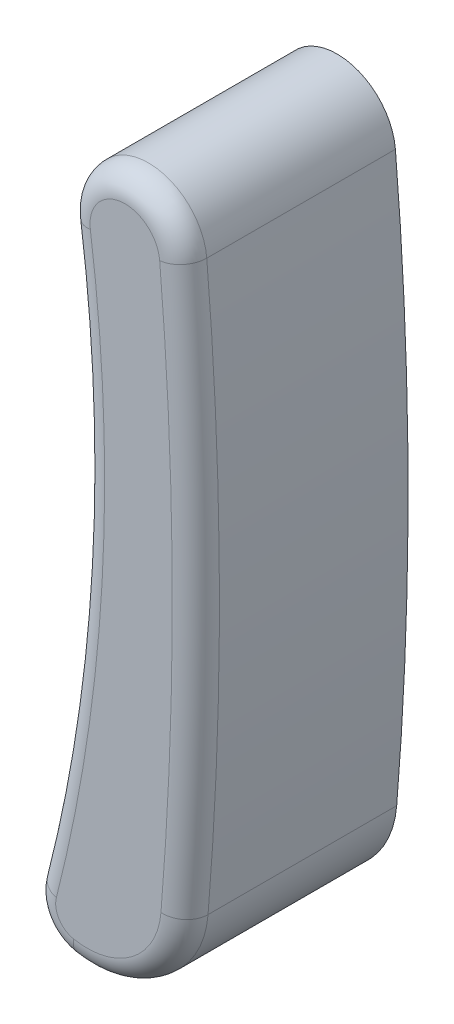
from build123d import *

# Parameters (mm, degrees)
EXTRUDE1_DEPTH = 4.5
FILLET1_R      = 0.5


with BuildPart() as part:
    # Sketch2 → Extrude1 (new body)
    with BuildSketch(Plane.XY):
        with BuildLine():
            ThreePointArc((1.467618759, 6.404104167), (0.094372819, 7.528980002), (-0.996737871, 6.128755907))
            ThreePointArc((-0.996737871, 6.128755907), (-0.750709422, -0.125968829), (-1.706502063, -6.312128537))
            ThreePointArc((-1.706502063, -6.312128537), (-1.584231252, -7.071852789), (-0.946059773, -7.501815872))
            ThreePointArc((-0.946059773, -7.501815872), (0.688671474, -7.111598822), (1.495022371, -5.637009447))
            ThreePointArc((1.495022371, -5.637009447), (1.73628539, 0.384127619), (1.467618759, 6.404104167))
        make_face()
    extrude(amount=EXTRUDE1_DEPTH)

    # Fillet1
    fillet1_edges = [part.edges().sort_by_distance(p)[0] for p in [
        (-0.750709422, -0.125968829, 4.5),
        (-1.584231252, -7.071852789, 4.5),
        (0.688671474, -7.111598822, 4.5),
        (1.73628539, 0.384127619, 4.5),
        (0.094372819, 7.528980002, 4.5),
    ]]
    fillet(fillet1_edges, radius=FILLET1_R)


solid = part.part
